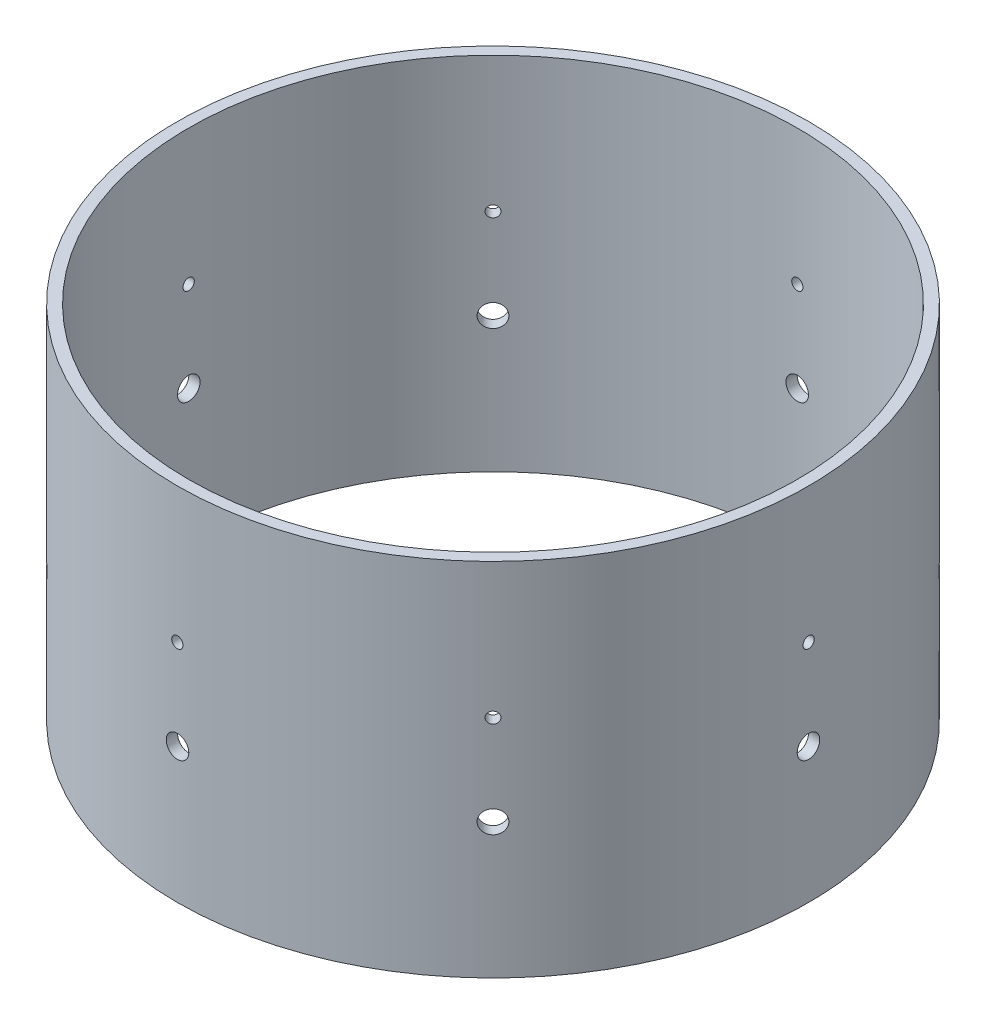
from build123d import *

# Parameters (mm, degrees)
SKETCH1_R           = 88.9
SKETCH1_R_2         = 85.725
BOSS_EXTRUDE1_DEPTH = 101.6
SKETCH2_R           = 1.5875
SKETCH2_R_2         = 3.175
CUT_EXTRUDE1_DEPTH  = 89.9
CIRPATTERN1_COUNT   = 8


with BuildPart() as part:
    # Sketch1 → Boss-Extrude1 (new body)
    with BuildSketch(Plane(origin=(0, 0, 0), x_dir=(1, 0, 0), z_dir=(0, 1, 0))):
        Circle(SKETCH1_R)
        Circle(SKETCH1_R_2, mode=Mode.SUBTRACT)
    extrude(amount=BOSS_EXTRUDE1_DEPTH)

    # Sketch2 → Cut-Extrude1 (cut, through all)
    with BuildSketch(Plane.XY):
        with Locations((0, 63.5)):
            Circle(SKETCH2_R)
        with Locations((0, 38.1)):
            Circle(SKETCH2_R_2)
    cut_extrude1 = extrude(amount=-CUT_EXTRUDE1_DEPTH, mode=Mode.SUBTRACT)

    # CirPattern1: Cut-Extrude1 ×8 about axis
    cirpattern1_axis = Axis((0, 0, 0), (0, 1, 0))
    for i in range(1, CIRPATTERN1_COUNT):
        add(cut_extrude1.rotate(cirpattern1_axis, i * 360 / CIRPATTERN1_COUNT), mode=Mode.SUBTRACT)


solid = part.part
